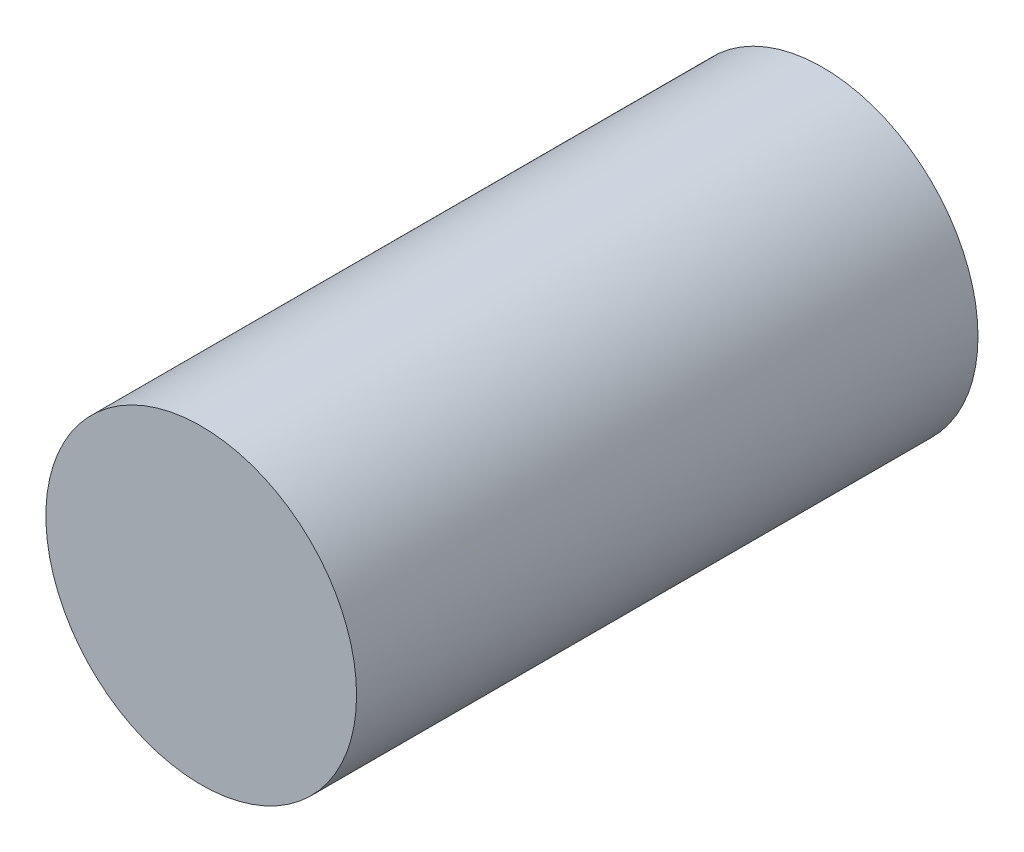
from build123d import *

# Parameters (mm, degrees)
CROQUIS1_R              = 0.5
SALIENTE_EXTRUIR1_DEPTH = 2


with BuildPart() as part:
    # Croquis1 → Saliente-Extruir1 (new body)
    with BuildSketch(Plane.XY):
        Circle(CROQUIS1_R)
    extrude(amount=SALIENTE_EXTRUIR1_DEPTH)


solid = part.part
